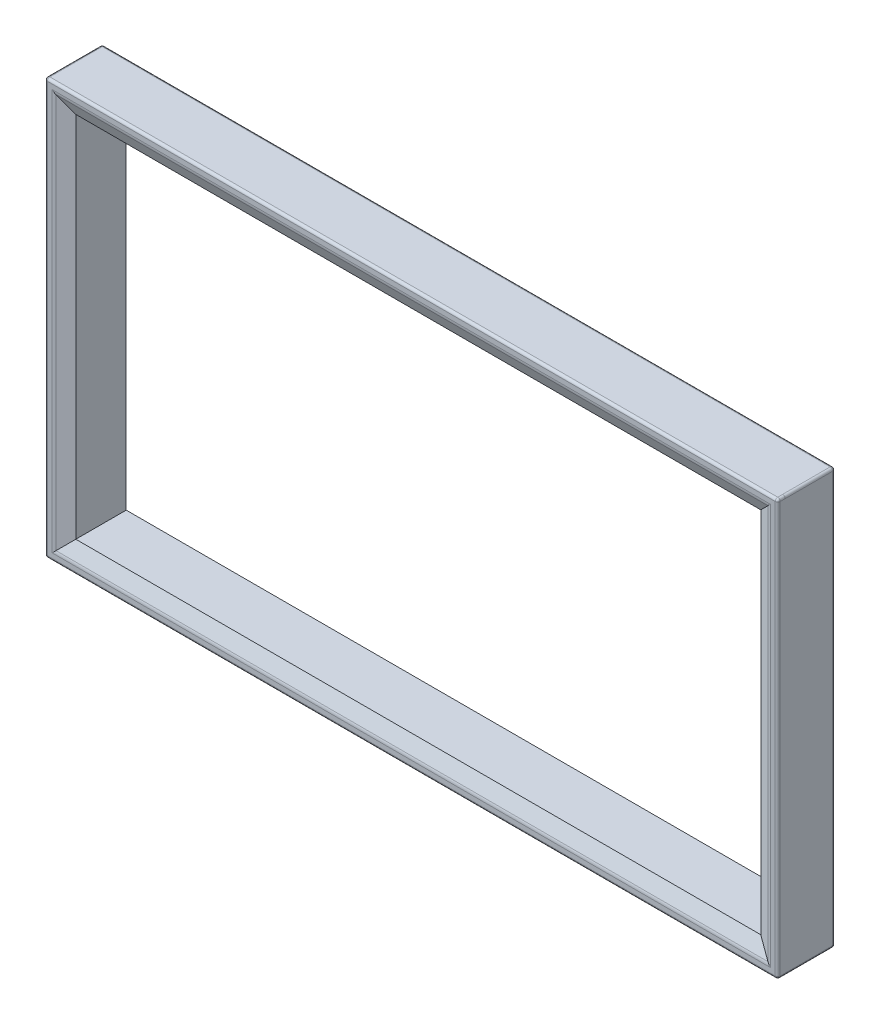
from build123d import *

# Parameters (mm, degrees)
SZKIC2_W                    = 2936
SZKIC2_H                    = 1666
SZKIC2_W_2                  = 2744
SZKIC2_H_2                  = 1474
DODANIE_WYCI_GNI_CIE1_DEPTH = 30
SFAZOWANIE1_SIZE            = 60
SFAZOWANIE1_SIZE2           = 27.978459489
ZAOKR_GLENIE1_R             = 30
ZAOKR_GLENIE2_R             = 10
SZKIC3_W                    = 2936
SZKIC3_H                    = 1666
SZKIC3_W_2                  = 2744
SZKIC3_H_2                  = 1474
DODANIE_WYCI_GNI_CIE2_DEPTH = 200
ZAOKR_GLENIE3_R             = 10


with BuildPart() as part:
    # Szkic2 → Dodanie-wyciągnięcie1 (new body)
    with BuildSketch(Plane.XY.offset(393)):
        with Locations((-66.247811398, -0.126850764)):
            Rectangle(SZKIC2_W, SZKIC2_H)
        with Locations((-66.247811398, -0.126850764)):
            Rectangle(SZKIC2_W_2, SZKIC2_H_2, mode=Mode.SUBTRACT)
    extrude(amount=DODANIE_WYCI_GNI_CIE1_DEPTH)

    # Sfazowanie1
    sfazowanie1_edges = [part.edges().sort_by_distance(p)[0] for p in [
        (1305.752188602, -0.126850764, 423),
        (-66.247811398, 736.873149236, 423),
        (-1438.247811398, -0.126850764, 423),
        (-66.247811398, -737.126850764, 423),
    ]]
    sfazowanie1_side = [part.faces().sort_by_distance(p)[0] for p in [
        (-66.247811398, -799.369404178, 423),
    ]]
    chamfer(sfazowanie1_edges, length=SFAZOWANIE1_SIZE, length2=SFAZOWANIE1_SIZE2, reference=sfazowanie1_side[0])

    # Zaokrąglenie1
    zaokr_glenie1_edges = [part.edges().sort_by_distance(p)[0] for p in [
        (-66.247811398, -797.126850764, 423),
        (1365.752188602, -0.126850764, 423),
        (-66.247811398, 796.873149236, 423),
        (-1498.247811398, -0.126850764, 423),
    ]]
    fillet(zaokr_glenie1_edges, radius=ZAOKR_GLENIE1_R)

    # Zaokrąglenie2
    zaokr_glenie2_edges = [part.edges().sort_by_distance(p)[0] for p in [
        (-1534.247811398, -0.126850764, 423),
        (-66.247811398, -833.126850764, 423),
        (1401.752188602, -0.126850764, 423),
        (-66.247811398, 832.873149236, 423),
        (1401.752188602, -833.126850764, 408),
        (-1534.247811398, -833.126850764, 408),
        (-1534.247811398, 832.873149236, 408),
        (1401.752188602, 832.873149236, 408),
    ]]
    fillet(zaokr_glenie2_edges, radius=ZAOKR_GLENIE2_R)

    # Szkic3 → Dodanie-wyciągnięcie2 (add)
    with BuildSketch(Plane(origin=(0, 0, 393), x_dir=(-1, 0, 0), z_dir=(0, 0, -1))):
        with Locations((66.247811398, -0.126850764)):
            Rectangle(SZKIC3_W, SZKIC3_H)
        with Locations((66.247811398, -0.126850764)):
            Rectangle(SZKIC3_W_2, SZKIC3_H_2, mode=Mode.SUBTRACT)
    extrude(amount=DODANIE_WYCI_GNI_CIE2_DEPTH)

    # Zaokrąglenie3
    zaokr_glenie3_edges = [part.edges().sort_by_distance(p)[0] for p in [
        (-1534.247811398, -833.126850764, 293),
        (-66.247811398, -833.126850764, 193),
        (1401.752188602, -833.126850764, 293),
        (1401.752188602, -0.126850764, 193),
        (1401.752188602, 832.873149236, 293),
        (-66.247811398, 832.873149236, 193),
        (-1534.247811398, -0.126850764, 193),
        (-1534.247811398, 832.873149236, 293),
    ]]
    fillet(zaokr_glenie3_edges, radius=ZAOKR_GLENIE3_R)


solid = part.part
